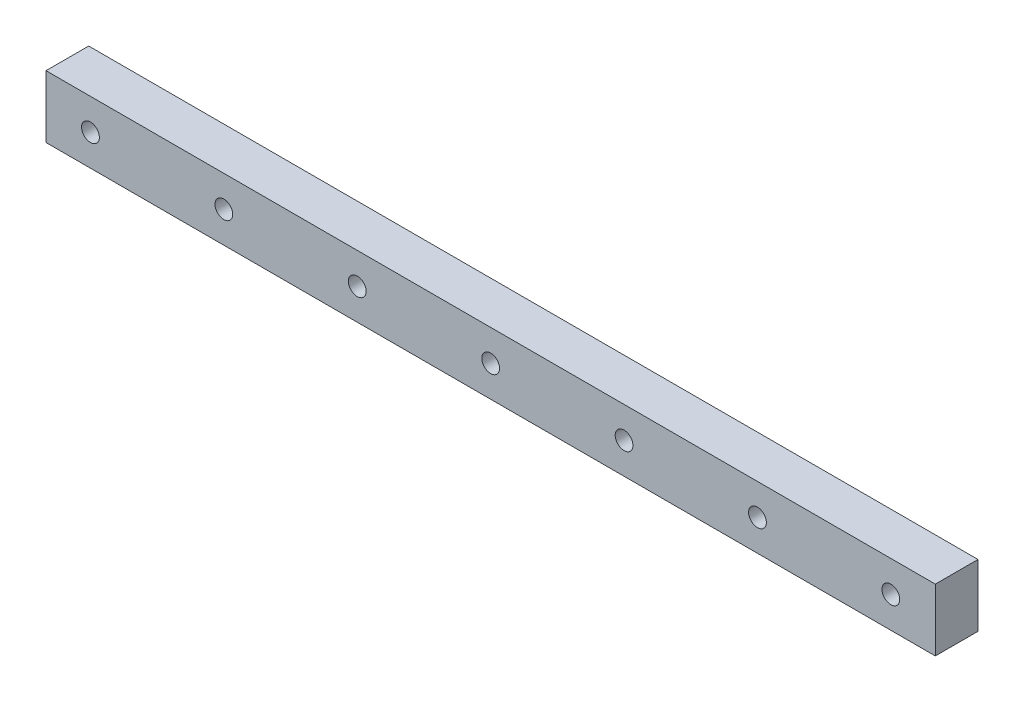
from build123d import *

# Parameters (mm, degrees)
SKETCH_1_W      = 100
SKETCH_1_H      = 7
SKETCH_1_R      = 1
EXTRUDE_1_DEPTH = 4.8


with BuildPart() as part:
    # 草图1 → 凸台-拉伸1 (new body)
    with BuildSketch(Plane.XY):
        with Locations((50, 3.5)):
            Rectangle(SKETCH_1_W, SKETCH_1_H)
        with Locations((5, 3.5)):
            Circle(SKETCH_1_R, mode=Mode.SUBTRACT)
        with Locations((20, 3.5)):
            Circle(SKETCH_1_R, mode=Mode.SUBTRACT)
        with Locations((35, 3.5)):
            Circle(SKETCH_1_R, mode=Mode.SUBTRACT)
        with Locations((50, 3.5)):
            Circle(SKETCH_1_R, mode=Mode.SUBTRACT)
        with Locations((65, 3.5)):
            Circle(SKETCH_1_R, mode=Mode.SUBTRACT)
        with Locations((80, 3.5)):
            Circle(SKETCH_1_R, mode=Mode.SUBTRACT)
        with Locations((95, 3.5)):
            Circle(SKETCH_1_R, mode=Mode.SUBTRACT)
    extrude(amount=EXTRUDE_1_DEPTH)


solid = part.part
